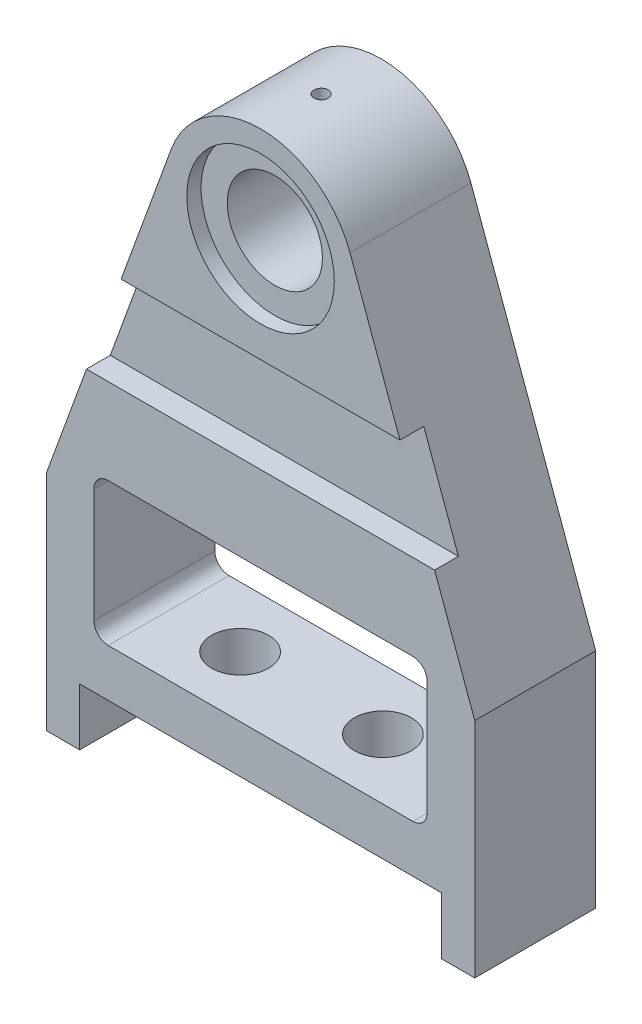
from build123d import *

# Parameters (mm, degrees)
SKETCH1_R          = 10
EXTRUDE1_DEPTH     = 25.4
CUT_EXTRUDE1_DEPTH = 26.4
CUT_EXTRUDE2_REACH = 122
SKETCH5_R          = 6
CUT_EXTRUDE3_REACH = 151
SKETCH6_R          = 1.5
SKETCH7_W          = 131.09029237
SKETCH7_H          = 20
EXTRUDE2_DEPTH     = 5
SKETCH8_R          = 15.5
SKETCH8_R_2        = 10
EXTRUDE3_DEPTH     = 3


with BuildPart() as part:
    # Sketch1 → Extrude1 (new body)
    with BuildSketch(Plane.XY):
        with BuildLine():
            Line((-38, 0), (38, 0))
            Line((38, 0), (38, -12))
            Line((38, -12), (45, -12))
            Line((45, -12), (45, 34.839604128))
            Line((45, 34.839604128), (18.793852416, 106.840402867))
            ThreePointArc((18.793852416, 106.840402867), (0, 120), (-18.793852416, 106.840402867))
            Line((-18.793852416, 106.840402867), (-45, 34.839604128))
            Line((-45, 34.839604128), (-45, -12))
            Line((-45, -12), (-38, -12))
            Line((-38, -12), (-38, 0))
        make_face()
        with Locations((0, 100)):
            Circle(SKETCH1_R, mode=Mode.SUBTRACT)
    extrude(amount=EXTRUDE1_DEPTH)

    # Sketch2 → Cut-Extrude1 (cut, through all)
    with BuildSketch(Plane.XY.offset(25.4)):
        with BuildLine():
            Line((-32, 10), (32, 10))
            ThreePointArc((32, 10), (34.121320344, 10.878679656), (35, 13))
            Line((35, 13), (35, 37))
            ThreePointArc((35, 37), (34.121320344, 39.121320344), (32, 40))
            Line((32, 40), (-32, 40))
            ThreePointArc((-32, 40), (-34.121320344, 39.121320344), (-35, 37))
            Line((-35, 37), (-35, 13))
            ThreePointArc((-35, 13), (-34.121320344, 10.878679656), (-32, 10))
        make_face()
    extrude(amount=-CUT_EXTRUDE1_DEPTH, mode=Mode.SUBTRACT)

    # Sketch5 → Cut-Extrude2 (cut, up to next)
    with BuildSketch(Plane.XZ, mode=Mode.PRIVATE) as cut_extrude2_sk1:
        with Locations((13, 12.7)):
            Circle(SKETCH5_R)
    cut_extrude2_tool1 = extrude(cut_extrude2_sk1.sketch, amount=-CUT_EXTRUDE2_REACH, mode=Mode.PRIVATE) & part.part
    add(cut_extrude2_tool1.solids().sort_by_distance((13, 0, 12.7))[0], mode=Mode.SUBTRACT)
    # Sketch5 → Cut-Extrude2 (cut, up to next)
    with BuildSketch(Plane.XZ, mode=Mode.PRIVATE) as cut_extrude2_sk2:
        with Locations((-17, 12.7)):
            Circle(SKETCH5_R)
    cut_extrude2_tool2 = extrude(cut_extrude2_sk2.sketch, amount=-CUT_EXTRUDE2_REACH, mode=Mode.PRIVATE) & part.part
    add(cut_extrude2_tool2.solids().sort_by_distance((-17, 0, 12.7))[0], mode=Mode.SUBTRACT)

    # Sketch6 → Cut-Extrude3 (cut, up to next)
    with BuildSketch(Plane(origin=(0, 137, 0), x_dir=(-1, 0, 0), z_dir=(0, 1, 0)), mode=Mode.PRIVATE) as cut_extrude3_sk1:
        with Locations((0, 12.7)):
            Circle(SKETCH6_R)
    cut_extrude3_tool1 = extrude(cut_extrude3_sk1.sketch, amount=-CUT_EXTRUDE3_REACH, mode=Mode.PRIVATE) & part.part
    add(cut_extrude3_tool1.solids().sort_by_distance((0, 137, 12.7))[0], mode=Mode.SUBTRACT)

    # Sketch7 → Extrude2 (cut)
    with BuildSketch(Plane.XY.offset(25.4)):
        with Locations((2.300736004, 68)):
            Rectangle(SKETCH7_W, SKETCH7_H)
    extrude(amount=-EXTRUDE2_DEPTH, mode=Mode.SUBTRACT)

    # Sketch8 → Extrude3 (cut)
    with BuildSketch(Plane.XY.offset(25.4)):
        with Locations((0, 100)):
            Circle(SKETCH8_R)
        with Locations((0, 100)):
            Circle(SKETCH8_R_2, mode=Mode.SUBTRACT)
    extrude3 = extrude(amount=-EXTRUDE3_DEPTH, mode=Mode.SUBTRACT)

    # Mirror1: Extrude3 across plane
    add(extrude3.mirror(Plane.XY.offset(12.7)), mode=Mode.SUBTRACT)


solid = part.part
